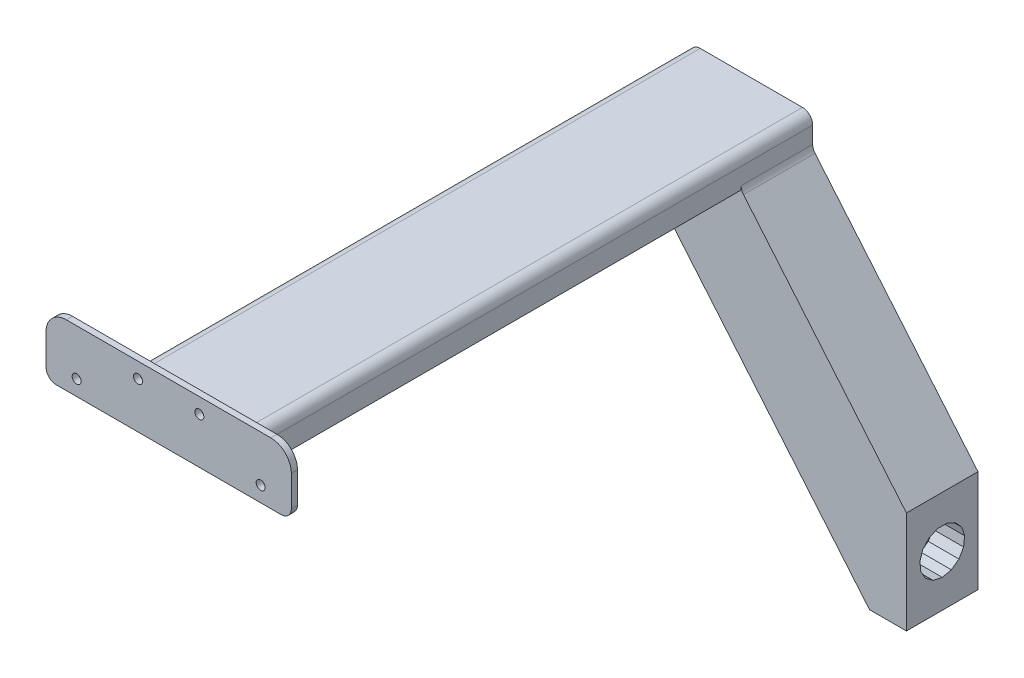
from build123d import *

# Parameters (mm, degrees)
BOSS_EXTRUDE1_DEPTH      = 35
CUT_EXTRUDE1_DEPTH       = 15
SKETCH3_W                = 40
SKETCH3_H                = 35
SKETCH3_W_2              = 20
BOSS_EXTRUDE2_DEPTH      = 5
BOSS_EXTRUDE3_DEPTH      = 35
SKETCH5_R                = 2.15
CUT_EXTRUDE2_DEPTH       = 10
SKETCH6_W                = 60
SKETCH6_H                = 15
BOSS_EXTRUDE4_DEPTH      = 250
BOSS_EXTRUDE4_DEPTH_BACK = 35
SKETCH7_W                = 35
SKETCH7_H                = 5
CUT_EXTRUDE3_DEPTH       = 35
SKETCH8_W                = 35
SKETCH8_H                = 5
CUT_EXTRUDE4_DEPTH       = 50
SKETCH9_W                = 30
SKETCH9_H                = 15
BOSS_EXTRUDE5_DEPTH      = 3
SKETCH10_R               = 2.2
CUT_EXTRUDE5_DEPTH       = 5
FILLET1_R                = 5
FILLET3_R                = 5
FILLET4_R                = 5
SKETCH12_W               = 120
SKETCH12_H               = 15
BOSS_EXTRUDE6_DEPTH      = 3
SKETCH13_R               = 2.2
CUT_EXTRUDE6_DEPTH       = 5
FILLET5_R                = 10
FILLET7_R                = 5


with BuildPart() as part:
    # Sketch1 → Boss-Extrude1 (new body)
    with BuildSketch(Plane.XY):
        Polygon((39.235591649, -281.893482393), (21.190573208, -281.893482393), (-105.827495151, -130.519243102), (-45.827495151, -130.519243102), (39.235591649, -231.893482393), align=None)
    extrude(amount=BOSS_EXTRUDE1_DEPTH)

    # Sketch2 → Cut-Extrude1 (cut)
    with BuildSketch(Plane(origin=(39.235591649, 0, 0), x_dir=(0, 0, -1), z_dir=(1, 0, 0))):
        Polygon((-19.787028599, -246.133858785), (-23.965637775, -247.994295455), (-27.026279442, -251.393482393), (-28.439740849, -255.743669297), (-27.961621679, -260.292669331), (-25.67459308, -264.253919063), (-21.974103074, -266.942482427), (-17.5, -267.893482393), (-13.025896926, -266.942482427), (-9.32540692, -264.253919063), (-7.038378321, -260.292669331), (-6.560259151, -255.743669297), (-7.973720558, -251.393482393), (-11.034362225, -247.994295455), (-15.212971401, -246.133858785), align=None)
    extrude(amount=-CUT_EXTRUDE1_DEPTH, mode=Mode.SUBTRACT)

    # Sketch3 → Boss-Extrude2 (add)
    with BuildSketch(Plane(origin=(0, -130.519243102, 0), x_dir=(1, 0, 0), z_dir=(0, 1, 0))):
        with Locations((-25.827495151, -17.5)):
            Rectangle(SKETCH3_W, SKETCH3_H)
        with Locations((-115.827495151, -17.5)):
            Rectangle(SKETCH3_W_2, SKETCH3_H)
    extrude(amount=-BOSS_EXTRUDE2_DEPTH)

    # Sketch4 → Boss-Extrude3 (add)
    with BuildSketch(Plane(origin=(0, 0, 0), x_dir=(-1, 0, 0), z_dir=(0, 0, -1))):
        Polygon((105.827495151, -130.519243102), (105.827495151, -135.519243102), (101.631996995, -135.519243102), align=None)
    extrude(amount=-BOSS_EXTRUDE3_DEPTH)

    # Sketch5 → Cut-Extrude2 (cut)
    with BuildSketch(Plane.XZ.offset(135.519243102)):
        with Locations((-23.729746073, 17.5)):
            Circle(SKETCH5_R)
        with Locations((-113.729746073, 17.5)):
            Circle(SKETCH5_R)
    extrude(amount=-CUT_EXTRUDE2_DEPTH, mode=Mode.SUBTRACT)

    # Sketch6 → Boss-Extrude4 (add, two sides)
    with BuildSketch(Plane.XY.offset(35)) as boss_extrude4_sk:
        with Locations((-71.631996995, -128.019243102)):
            Rectangle(SKETCH6_W, SKETCH6_H)
    extrude(amount=BOSS_EXTRUDE4_DEPTH)
    extrude(boss_extrude4_sk.sketch, amount=-BOSS_EXTRUDE4_DEPTH_BACK)

    # Sketch7 → Cut-Extrude3 (cut)
    with BuildSketch(Plane.ZY.offset(101.631996995)):
        with Locations((17.5, -133.019243102)):
            Rectangle(SKETCH7_W, SKETCH7_H)
    extrude(amount=CUT_EXTRUDE3_DEPTH, mode=Mode.SUBTRACT)

    # Sketch8 → Cut-Extrude4 (cut)
    with BuildSketch(Plane(origin=(-41.631996995, 0, 0), x_dir=(0, 0, -1), z_dir=(1, 0, 0))):
        with Locations((-17.5, -133.019243102)):
            Rectangle(SKETCH8_W, SKETCH8_H)
    extrude(amount=CUT_EXTRUDE4_DEPTH, mode=Mode.SUBTRACT)

    # Sketch9 → Boss-Extrude5 (add)
    with BuildSketch(Plane.XY.offset(285)):
        with Locations((-116.631996995, -128.019243102)):
            Rectangle(SKETCH9_W, SKETCH9_H)
        with Locations((-26.631996995, -128.019243102)):
            Rectangle(SKETCH9_W, SKETCH9_H)
    extrude(amount=-BOSS_EXTRUDE5_DEPTH)

    # Sketch10 → Cut-Extrude5 (cut)
    with BuildSketch(Plane(origin=(0, 0, 282), x_dir=(-1, 0, 0), z_dir=(0, 0, -1))):
        with Locations((26.631996995, -128.019243102)):
            Circle(SKETCH10_R)
        with Locations((116.631996995, -128.019243102)):
            Circle(SKETCH10_R)
    extrude(amount=-CUT_EXTRUDE5_DEPTH, mode=Mode.SUBTRACT)

    # Fillet1
    fillet1_edges = [part.edges().sort_by_distance(p)[0] for p in [
        (-41.631996995, -135.519243102, 17.5),
    ]]
    fillet(fillet1_edges, radius=FILLET1_R)

    # Fillet3
    fillet3_edges = [part.edges().sort_by_distance(p)[0] for p in [
        (-41.631996995, -120.519243102, 141),
    ]]
    fillet(fillet3_edges, radius=FILLET3_R)

    # Fillet4
    fillet4_edges = [part.edges().sort_by_distance(p)[0] for p in [
        (-101.631996995, -120.519243102, 141),
    ]]
    fillet(fillet4_edges, radius=FILLET4_R)

    # Sketch12 → Boss-Extrude6 (add)
    with BuildSketch(Plane(origin=(0, 0, 282), x_dir=(-1, 0, 0), z_dir=(0, 0, -1))):
        with Locations((71.631996995, -113.019243102)):
            Rectangle(SKETCH12_W, SKETCH12_H)
    extrude(amount=-BOSS_EXTRUDE6_DEPTH)

    # Sketch13 → Cut-Extrude6 (cut)
    with BuildSketch(Plane(origin=(0, 0, 282), x_dir=(-1, 0, 0), z_dir=(0, 0, -1))):
        with Locations((56.631996995, -113.019243102)):
            Circle(SKETCH13_R)
        with Locations((86.631996995, -113.019243102)):
            Circle(SKETCH13_R)
    extrude(amount=-CUT_EXTRUDE6_DEPTH, mode=Mode.SUBTRACT)

    # Fillet5
    fillet5_edges = [part.edges().sort_by_distance(p)[0] for p in [
        (-11.631996995, -105.519243102, 283.5),
        (-131.631996995, -105.519243102, 283.5),
    ]]
    fillet(fillet5_edges, radius=FILLET5_R)

    # Fillet7
    fillet7_edges = [part.edges().sort_by_distance(p)[0] for p in [
        (-131.631996995, -135.519243102, 283.5),
        (-11.631996995, -135.519243102, 283.5),
    ]]
    fillet(fillet7_edges, radius=FILLET7_R)


solid = part.part
